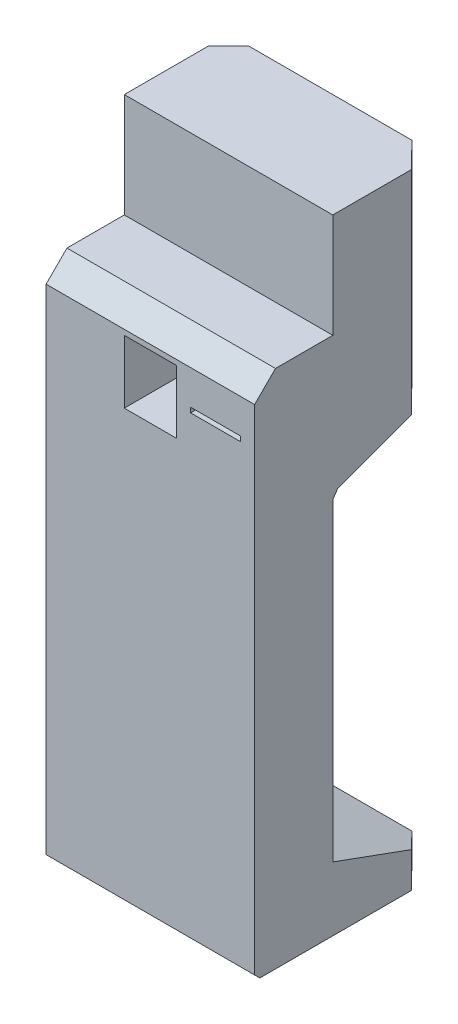
from build123d import *

# Parameters (mm, degrees)
BOSS_EXTRUDE1_DEPTH     = 400
SKETCH2_W               = 100
SKETCH2_H               = 121
SKETCH2_W_2             = 95.3
SKETCH2_H_2             = 9.4
CUT_EXTRUDE1_DEPTH      = 268
CUT_EXTRUDE2_DEPTH      = 1
CUT_EXTRUDE2_DEPTH_BACK = 1198.763658591


with BuildPart() as part:
    # Sketch1 → Boss-Extrude1 (new body)
    with BuildSketch(Plane(origin=(0, 0, 0), x_dir=(0, 0, -1), z_dir=(1, 0, 0))):
        Polygon((0, 0), (-340, 0), (-350, 10), (-350, 957.763658591), (-310, 997.763658591), (-200, 997.763658591), (-200, 1197.763658591), (-150, 1197.763658591), (0, 1197.763658591), (0, 997.763658591), (0, 967.763658591), (0, 817.763658591), (-9.396926208, 804.343457158), (-27.474774195, 797.763658591), (-190.603073792, 738.389813171), (-200, 724.969611738), (-200, 122.794046853), (0, 50), align=None)
    extrude(amount=BOSS_EXTRUDE1_DEPTH)

    # Sketch2 → Cut-Extrude1 (cut)
    with BuildSketch(Plane.XY.offset(350)):
        with Locations((200, 887.263658591)):
            Rectangle(SKETCH2_W, SKETCH2_H)
        with Locations((325, 887.263658591)):
            Rectangle(SKETCH2_W_2, SKETCH2_H_2)
    extrude(amount=-CUT_EXTRUDE1_DEPTH, mode=Mode.SUBTRACT)

    # Sketch3 → Cut-Extrude2 (cut, two sides)
    with BuildSketch(Plane(origin=(0, 0, 0), x_dir=(-1, 0, 0), z_dir=(0, -1, 0))) as cut_extrude2_sk:
        Polygon((32.971910004, -72.804395349), (-67.728153305, 29.569560354), (-322.648629759, 29.569560354), (-423.348693067, -72.804395349), (-423.348693067, 100.069531779), (32.971910004, 100.069531779), align=None)
    extrude(amount=CUT_EXTRUDE2_DEPTH, mode=Mode.SUBTRACT)
    extrude(cut_extrude2_sk.sketch, amount=-CUT_EXTRUDE2_DEPTH_BACK, mode=Mode.SUBTRACT)


solid = part.part
